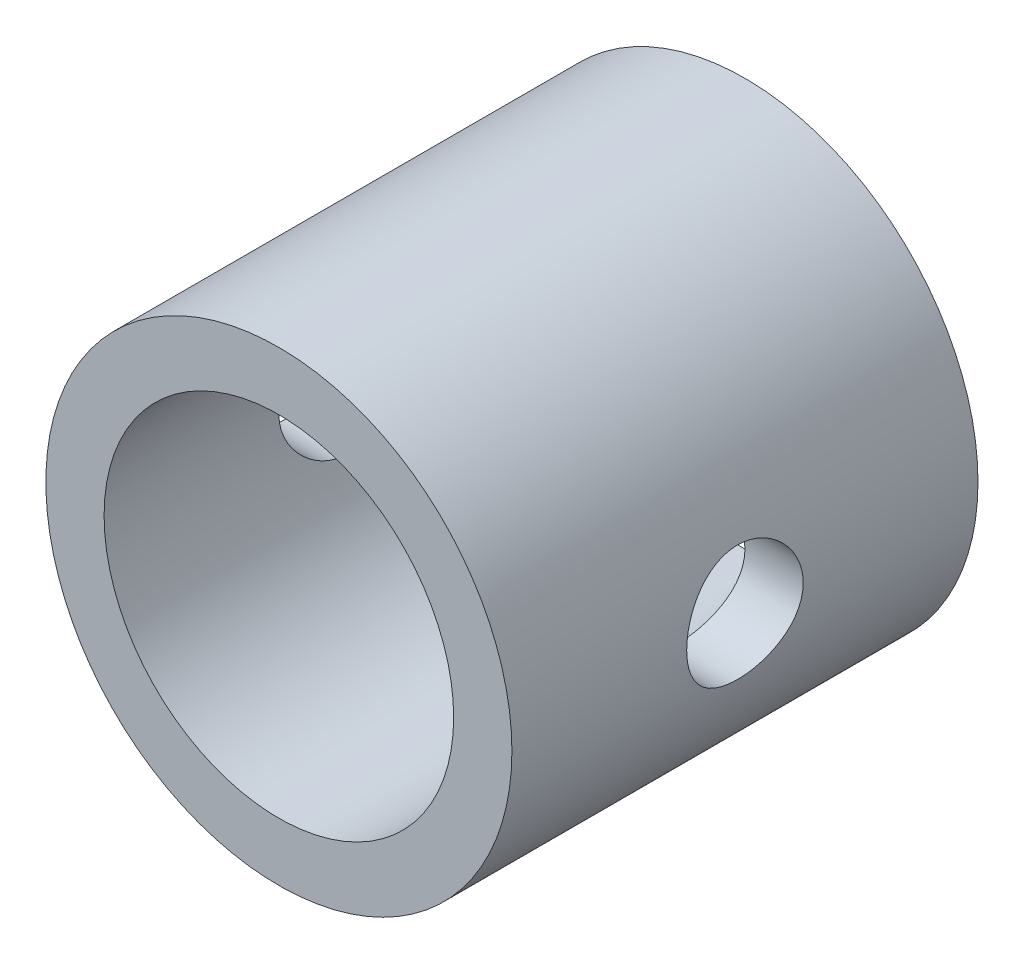
from build123d import *

# Parameters (mm, degrees)
SKETCH1_R               = 10
SKETCH1_R_2             = 7.5
BOSS_EXTRUDE1_DEPTH     = 20
SKETCH2_R               = 2.5
CUT_EXTRUDE1_DEPTH      = 11
CUT_EXTRUDE1_DEPTH_BACK = 11


with BuildPart() as part:
    # Sketch1 → Boss-Extrude1 (new body)
    with BuildSketch(Plane.XY):
        Circle(SKETCH1_R)
        Circle(SKETCH1_R_2, mode=Mode.SUBTRACT)
    extrude(amount=BOSS_EXTRUDE1_DEPTH)

    # Sketch2 → Cut-Extrude1 (cut, two sides)
    with BuildSketch(Plane(origin=(0, 0, 0), x_dir=(0, 0, -1), z_dir=(1, 0, 0))) as cut_extrude1_sk:
        with Locations((-10, 0)):
            Circle(SKETCH2_R)
    extrude(amount=CUT_EXTRUDE1_DEPTH, mode=Mode.SUBTRACT)
    extrude(cut_extrude1_sk.sketch, amount=-CUT_EXTRUDE1_DEPTH_BACK, mode=Mode.SUBTRACT)


solid = part.part
